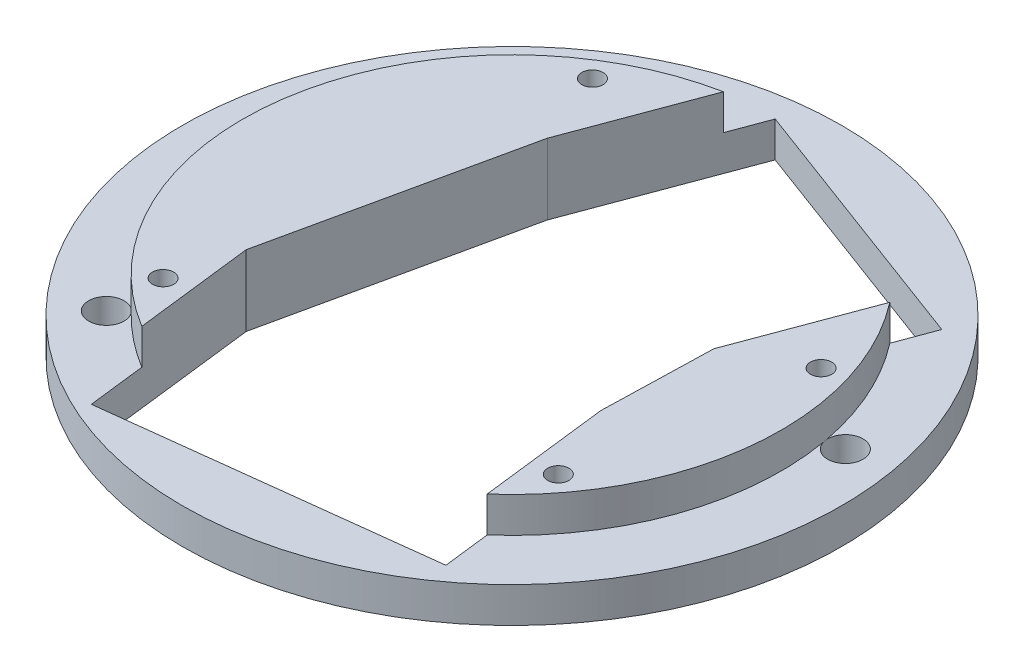
from build123d import *

# Parameters (mm, degrees)
ESQUISSE1_R             = 46.5
BOSS_EXTRU_1_DEPTH      = 5
ESQUISSE3_R             = 38
BOSS_EXTRU_2_DEPTH      = 5
ESQUISSE4_R             = 2.5
ENL_V_MAT_EXTRU_1_DEPTH = 6
ESQUISSE5_R             = 1.5
ENL_V_MAT_EXTRU_2_DEPTH = 11
ENL_V_MAT_EXTRU_4_DEPTH = 11
ENL_V_MAT_EXTRU_5_DEPTH = 11
ENL_V_MAT_EXTRU_6_DEPTH = 11


with BuildPart() as part:
    # Esquisse1 → Boss.-Extru.1 (new body)
    with BuildSketch(Plane(origin=(0, 0, 0), x_dir=(1, 0, 0), z_dir=(0, 1, 0))):
        with Locations(Location((-2.835211314, 0, 0), (0, 0, 270))):  # turned: the seam where the file's is
            Circle(ESQUISSE1_R)
    extrude(amount=BOSS_EXTRU_1_DEPTH)

    # Esquisse3 → Boss.-Extru.2 (add)
    with BuildSketch(Plane(origin=(0, 5, 0), x_dir=(1, 0, 0), z_dir=(0, 1, 0))):
        with Locations(Location((-2.835211314, 0, 0), (0, 0, 270))):  # turned: the seam where the file's is
            Circle(ESQUISSE3_R)
    extrude(amount=BOSS_EXTRU_2_DEPTH)

    # Esquisse4 → Enlèv. mat.-Extru.1 (cut, through all)
    with BuildSketch(Plane(origin=(0, 5, 0), x_dir=(1, 0, 0), z_dir=(0, 1, 0))):
        with Locations(Location((-21.248861584, 36.049258979, 0), (0, 0, 270))):  # turned: the seam where the file's is
            Circle(ESQUISSE4_R)
        with Locations(Location((36.99885245, 7.201316076, 0), (0, 0, 270))):  # turned: the seam where the file's is
            Circle(ESQUISSE4_R)
        with Locations(Location((-32.01877618, -28.052292793, 0), (0, 0, 270))):  # turned: the seam where the file's is
            Circle(ESQUISSE4_R)
    extrude(amount=-ENL_V_MAT_EXTRU_1_DEPTH, mode=Mode.SUBTRACT)

    # Esquisse5 → Enlèv. mat.-Extru.2 (cut, through all)
    with BuildSketch(Plane(origin=(0, 10, 0), x_dir=(1, 0, 0), z_dir=(0, 1, 0))):
        with Locations(Location((-27.01877618, -25.04959308, 0), (0, 0, 270))):  # turned: the seam where the file's is
            Circle(ESQUISSE5_R)
        with Locations(Location((24.833784646, -21.136546209, 0), (0, 0, 270))):  # turned: the seam where the file's is
            Circle(ESQUISSE5_R)
        with Locations(Location((30.401495955, 10.375365678, 0), (0, 0, 270))):  # turned: the seam where the file's is
            Circle(ESQUISSE5_R)
        with Locations(Location((-21.116944618, 29.632839055, 0), (0, 0, 270))):  # turned: the seam where the file's is
            Circle(ESQUISSE5_R)
    extrude(amount=-ENL_V_MAT_EXTRU_2_DEPTH, mode=Mode.SUBTRACT)

    # Esquisse6 → Enlèv. mat.-Extru.4 (cut, through all)
    with BuildSketch(Plane(origin=(0, 10, 0), x_dir=(1, 0, 0), z_dir=(0, 1, 0))):
        Polygon((-17.016589785, 19.158599311), (-8.28612786, 42.584632577), (29.195500656, 28.615902705), (20.465038731, 5.189869439), align=None)
    extrude(amount=-ENL_V_MAT_EXTRU_4_DEPTH, mode=Mode.SUBTRACT)

    # Esquisse7 → Enlèv. mat.-Extru.5 (cut, through all)
    with BuildSketch(Plane(origin=(0, 10, 0), x_dir=(1, 0, 0), z_dir=(0, 1, 0))):
        Polygon((-24.638086397, -15.703679396), (-21.665671556, -40.526345449), (23.01512734, -35.175998737), (20.0427125, -10.353332683), align=None)
    extrude(amount=-ENL_V_MAT_EXTRU_5_DEPTH, mode=Mode.SUBTRACT)

    # Esquisse8 → Enlèv. mat.-Extru.6 (cut, through all)
    with BuildSketch(Plane(origin=(0, 10, 0), x_dir=(1, 0, 0), z_dir=(0, 1, 0))):
        Polygon((-17.016589785, 19.158599311), (-24.638086397, -15.703679396), (20.0427125, -10.353332683), (20.465038731, 5.189869439), align=None)
    extrude(amount=-ENL_V_MAT_EXTRU_6_DEPTH, mode=Mode.SUBTRACT)


solid = part.part
